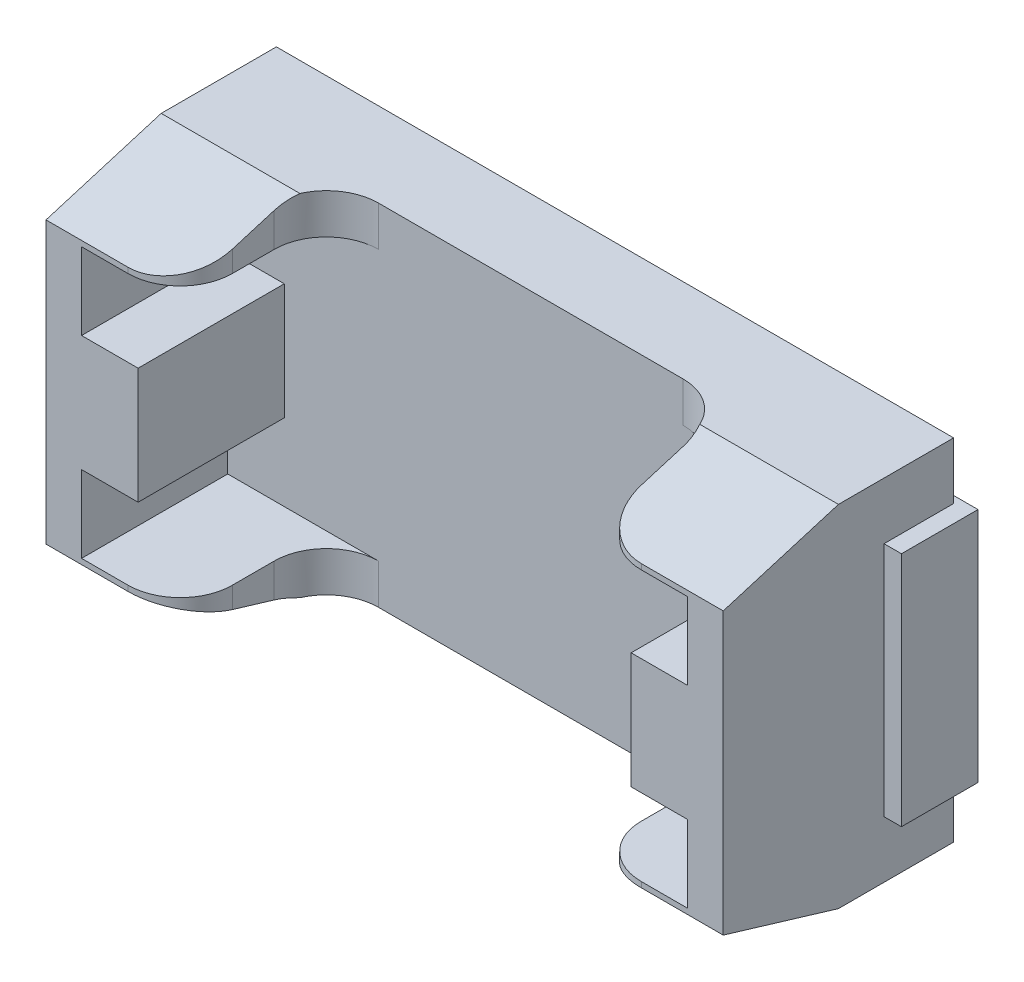
from build123d import *

# Parameters (mm, degrees)
ESQUISSE1_W             = 9.73
ESQUISSE1_H             = 5.03
BOSS_EXTRU_1_DEPTH      = 3.31
ESQUISSE3_W             = 3.841312789
ESQUISSE3_H             = 3.396529204
BOSS_EXTRU_2_DEPTH      = 0.1
BOSS_EXTRU_2_DEPTH_BACK = 1
ENL_V_MAT_EXTRU_1_DEPTH = 10.98001124
ESQUISSE5_W             = 5.874071128
ESQUISSE5_H             = 5.928896842
ENL_V_MAT_EXTRU_2_DEPTH = 2.1
ENL_V_MAT_EXTRU_4_DEPTH = 2.1
CONG_1_R                = 0.75
CONG_2_R                = 0.75


with BuildPart() as part:
    # Esquisse1 → Boss.-Extru.1 (new body)
    with BuildSketch(Plane.XY):
        Rectangle(ESQUISSE1_W, ESQUISSE1_H)
    extrude(amount=BOSS_EXTRU_1_DEPTH)

    # Esquisse3 → Boss.-Extru.2 (add, two sides)
    with BuildSketch(Plane(origin=(0, 0, 0), x_dir=(-1, 0, 0), z_dir=(0, 0, -1))) as boss_extru_2_sk:
        with Locations((-3.194354846, 0)):
            Rectangle(ESQUISSE3_W, ESQUISSE3_H)
        with Locations((3.194354846, 0)):
            Rectangle(ESQUISSE3_W, ESQUISSE3_H)
    extrude(amount=BOSS_EXTRU_2_DEPTH)
    extrude(boss_extru_2_sk.sketch, amount=-BOSS_EXTRU_2_DEPTH_BACK)

    # Esquisse4 → Enlèv. mat.-Extru.1 (cut, through all)
    with BuildSketch(Plane(origin=(4.865, 0, 0), x_dir=(0, 0, -1), z_dir=(1, 0, 0))):
        Polygon((-1.655, -2.515), (-3.31, -2.017151535), (-3.31, 2.017151535), (-1.655, 2.515), (-1.655, 2.602439027), (-3.426184741, 2.639019495), (-3.454926537, -2.688664416), (-1.655, -2.688664416), align=None)
    extrude(amount=-ENL_V_MAT_EXTRU_1_DEPTH, mode=Mode.SUBTRACT)

    # Esquisse5 → Enlèv. mat.-Extru.2 (cut)
    with BuildSketch(Plane.XY.offset(3.31)):
        with Locations((0, 0.049057066)):
            Rectangle(ESQUISSE5_W, ESQUISSE5_H)
    extrude(amount=-ENL_V_MAT_EXTRU_2_DEPTH, mode=Mode.SUBTRACT)

    # Esquisse6 → Enlèv. mat.-Extru.4 (cut)
    with BuildSketch(Plane.XY.offset(3.31)):
        Polygon((-2.937035564, 1.938709767), (-2.937035564, -1.938709767), (4.353991242, -1.938709767), (4.353991242, -0.833970123), (3.541647976, -0.833970123), (3.541647976, 0.833970123), (4.353991242, 0.833970123), (4.353991242, 1.938709767), align=None)
        Polygon((-4.353991242, -0.833970123), (-4.353991242, -1.938709767), (-2.937035564, -1.938709767), (-2.937035564, 1.938709767), (-4.353991242, 1.938709767), (-4.353991242, 0.833970123), (-3.541647976, 0.833970123), (-3.541647976, -0.833970123), align=None)
    extrude(amount=-ENL_V_MAT_EXTRU_4_DEPTH, mode=Mode.SUBTRACT)

    # Congé1
    cong_1_edges = [part.edges().sort_by_distance(p)[0] for p in [
        (-2.937035564, 2.226854883, 1.21),
        (2.937035564, 2.226854883, 1.21),
        (2.937035564, -2.226854883, 1.21),
        (-2.937035564, -2.226854883, 1.21),
    ]]
    fillet(cong_1_edges, radius=CONG_1_R)

    # Congé2
    cong_2_edges = [part.edges().sort_by_distance(p)[0] for p in [
        (2.937035564, 1.977930651, 3.31),
        (-2.937035564, -1.977930651, 3.31),
        (-2.937035564, 1.977930651, 3.31),
        (2.937035564, -1.977930651, 3.31),
    ]]
    fillet(cong_2_edges, radius=CONG_2_R)


solid = part.part
